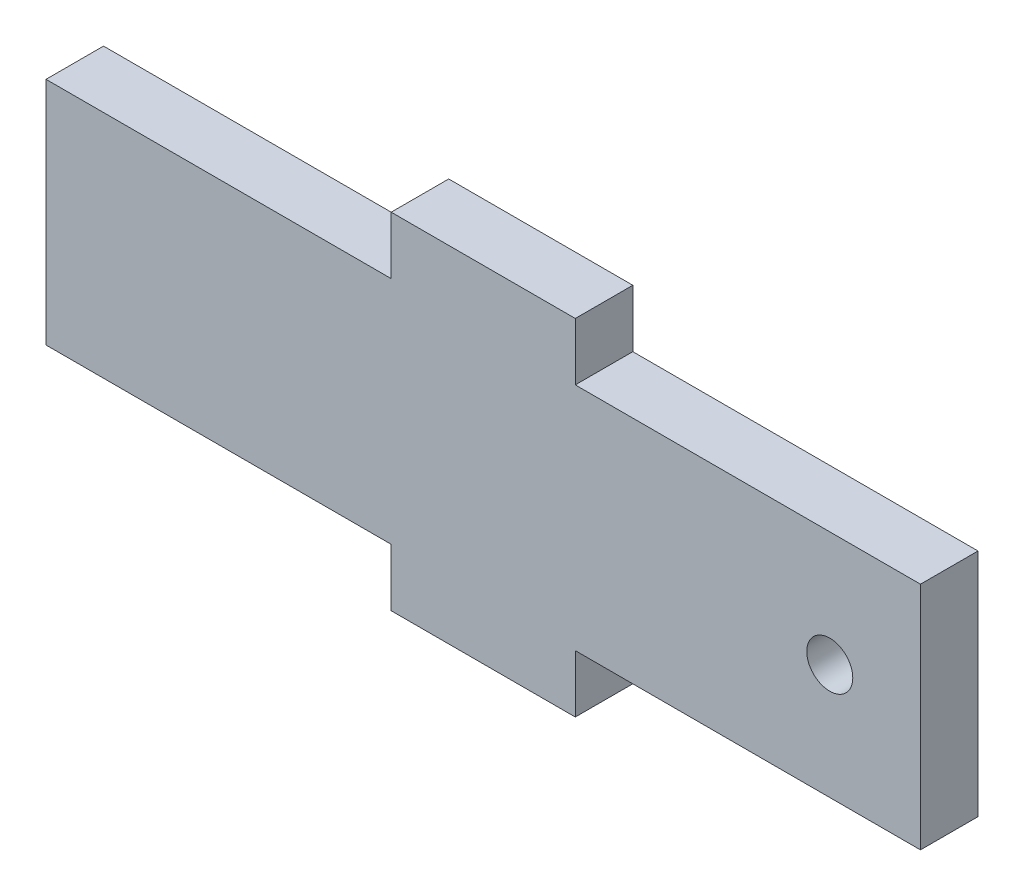
from build123d import *

# Parameters (mm, degrees)
SKETCH1_R           = 2
BOSS_EXTRUDE1_DEPTH = 5


with BuildPart() as part:
    # Sketch1 → Boss-Extrude1 (new body)
    with BuildSketch(Plane.XY):
        Polygon((-8, 10), (-8, 15), (8, 15), (8, 10), (38, 10), (38, -10), (8, -10), (8, -15), (-8, -15), (-8, -10), (-38, -10), (-38, 10), align=None)
        with Locations((30.117717463, 0)):
            Circle(SKETCH1_R, mode=Mode.SUBTRACT)
    extrude(amount=BOSS_EXTRUDE1_DEPTH)


solid = part.part
